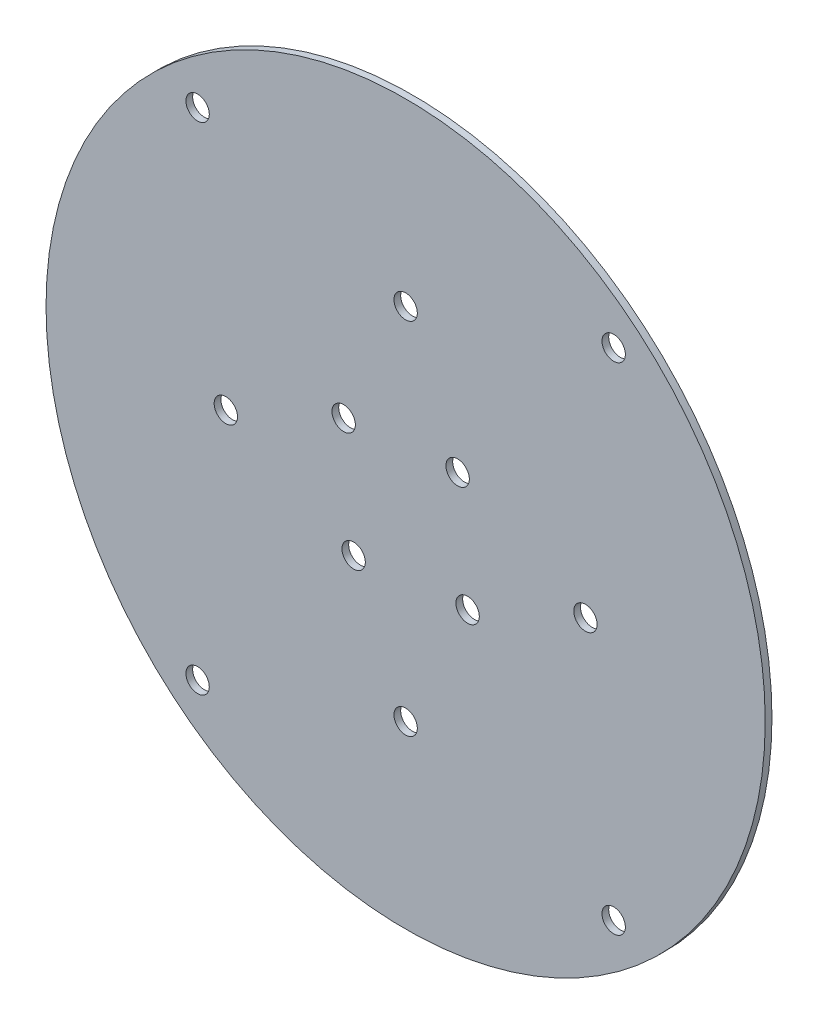
from build123d import *

# Parameters (mm, degrees)
SKETCH1_R           = 80
SKETCH1_R_2         = 2.6
BOSS_EXTRUDE1_DEPTH = 1.5
SKETCH2_R           = 2.6
CUT_EXTRUDE1_DEPTH  = 10
CIRPATTERN1_COUNT   = 4


with BuildPart() as part:
    # Sketch1 → Boss-Extrude1 (new body)
    with BuildSketch(Plane.XY):
        Circle(SKETCH1_R)
        with Locations((-46.280707897, 55.155199905)):
            Circle(SKETCH1_R_2, mode=Mode.SUBTRACT)
        with Locations((-46.280707897, -55.155199905)):
            Circle(SKETCH1_R_2, mode=Mode.SUBTRACT)
        with Locations((46.280707897, -55.155199905)):
            Circle(SKETCH1_R_2, mode=Mode.SUBTRACT)
        with Locations((46.280707897, 55.155199905)):
            Circle(SKETCH1_R_2, mode=Mode.SUBTRACT)
        with Locations((0, 40)):
            Circle(SKETCH1_R_2, mode=Mode.SUBTRACT)
        with Locations((40, 0)):
            Circle(SKETCH1_R_2, mode=Mode.SUBTRACT)
        with Locations((0, -40)):
            Circle(SKETCH1_R_2, mode=Mode.SUBTRACT)
        with Locations((-40, 0)):
            Circle(SKETCH1_R_2, mode=Mode.SUBTRACT)
    extrude(amount=BOSS_EXTRUDE1_DEPTH)

    # Sketch2 → Cut-Extrude1 (cut)
    with BuildSketch(Plane(origin=(0, 0, 0), x_dir=(-1, 0, 0), z_dir=(0, 0, -1))):
        with Locations((-11.570176974, 13.788799976)):
            Circle(SKETCH2_R)
    cut_extrude1 = extrude(amount=-CUT_EXTRUDE1_DEPTH, mode=Mode.SUBTRACT)

    # CirPattern1: Cut-Extrude1 ×4 about axis
    cirpattern1_axis = Axis((0, 0, 0), (0, 0, 1))
    for i in range(1, CIRPATTERN1_COUNT):
        add(cut_extrude1.rotate(cirpattern1_axis, i * 360 / CIRPATTERN1_COUNT), mode=Mode.SUBTRACT)


solid = part.part
